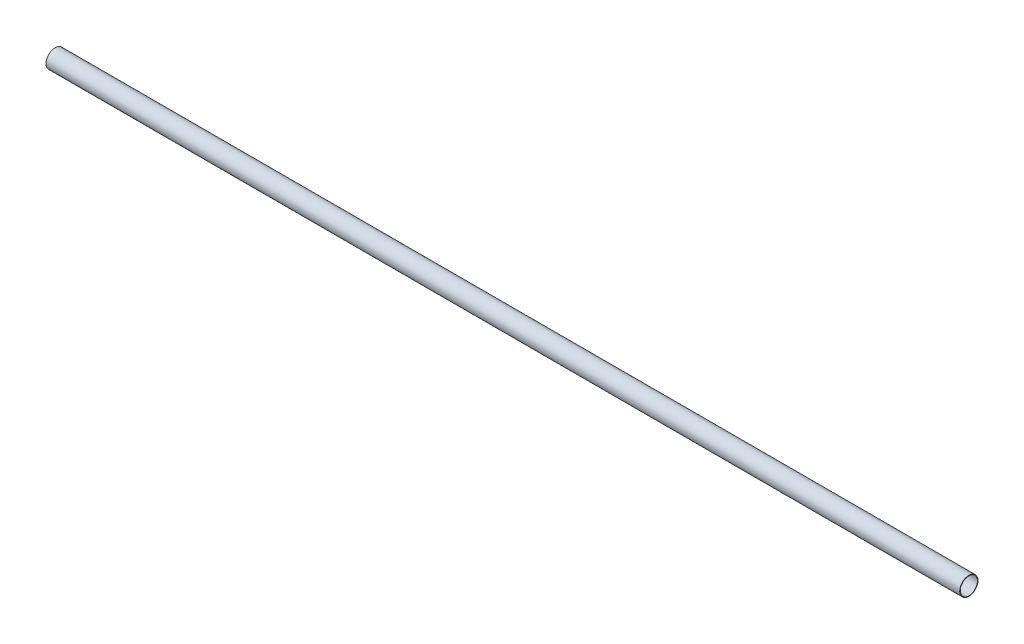
from build123d import *

# Parameters (mm, degrees)
SKETCH1_R           = 25
SKETCH1_R_2         = 23.5
BOSS_EXTRUDE1_DEPTH = 2500


with BuildPart() as part:
    # Sketch1 → Boss-Extrude1 (new body)
    with BuildSketch(Plane(origin=(0, 0, 0), x_dir=(0, 0, -1), z_dir=(1, 0, 0))):
        Circle(SKETCH1_R)
        Circle(SKETCH1_R_2, mode=Mode.SUBTRACT)
    extrude(amount=BOSS_EXTRUDE1_DEPTH)


solid = part.part
